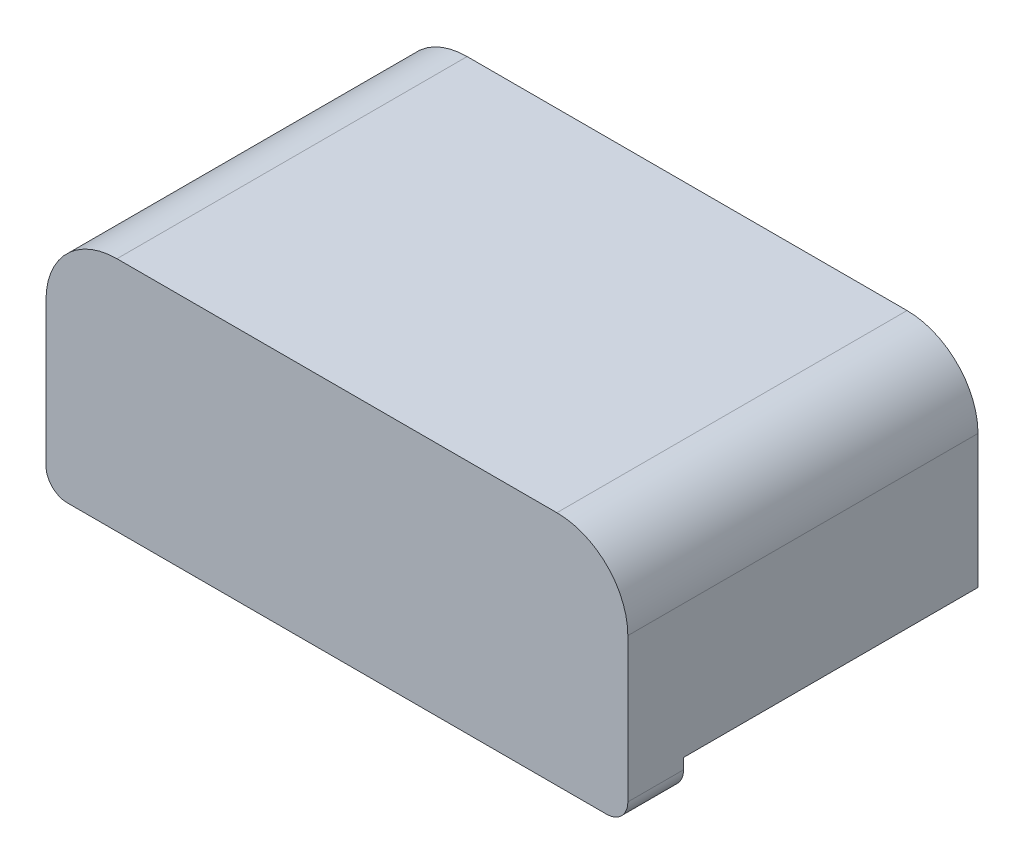
from build123d import *

# Parameters (mm, degrees)
SKETCH1_W           = 8.2
SKETCH1_H           = 3.33
BOSS_EXTRUDE1_DEPTH = 0.785
SKETCH2_W           = 8.2
SKETCH2_H           = 2.88
BOSS_EXTRUDE2_DEPTH = 4.15
FILLET1_R           = 1
FILLET2_R           = 0.3


with BuildPart() as part:
    # Sketch1 → Boss-Extrude1 (new body)
    with BuildSketch(Plane.XY):
        with Locations((0, 1.215)):
            Rectangle(SKETCH1_W, SKETCH1_H)
    extrude(amount=BOSS_EXTRUDE1_DEPTH)

    # Sketch2 → Boss-Extrude2 (add)
    with BuildSketch(Plane(origin=(0, 0, 0), x_dir=(-1, 0, 0), z_dir=(0, 0, -1))):
        with Locations((0, 1.44)):
            Rectangle(SKETCH2_W, SKETCH2_H)
    extrude(amount=BOSS_EXTRUDE2_DEPTH)

    # Fillet1
    fillet1_edges = [part.edges().sort_by_distance(p)[0] for p in [
        (-4.1, 2.88, -1.6825),
        (4.1, 2.88, -1.6825),
    ]]
    fillet(fillet1_edges, radius=FILLET1_R)

    # Fillet2
    fillet2_edges = [part.edges().sort_by_distance(p)[0] for p in [
        (4.1, -0.45, 0.3925),
        (-4.1, -0.45, 0.3925),
    ]]
    fillet(fillet2_edges, radius=FILLET2_R)


solid = part.part
